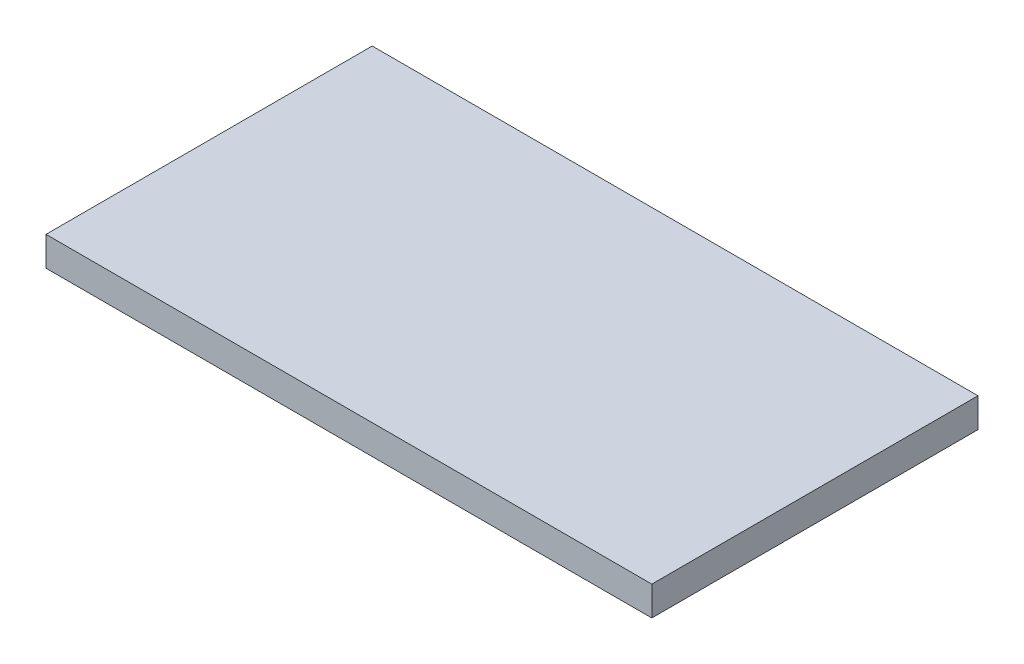
from build123d import *

# Parameters (mm, degrees)
SKETCH1_W           = 33.02
SKETCH1_H           = 17.78
BOSS_EXTRUDE2_DEPTH = 1.6


with BuildPart() as part:
    # Sketch1 → Boss-Extrude2 (new body)
    with BuildSketch(Plane(origin=(0, 0, 0), x_dir=(1, 0, 0), z_dir=(0, 1, 0))):
        with Locations((12.7, 7.62)):
            Rectangle(SKETCH1_W, SKETCH1_H)
    extrude(amount=BOSS_EXTRUDE2_DEPTH)


solid = part.part
